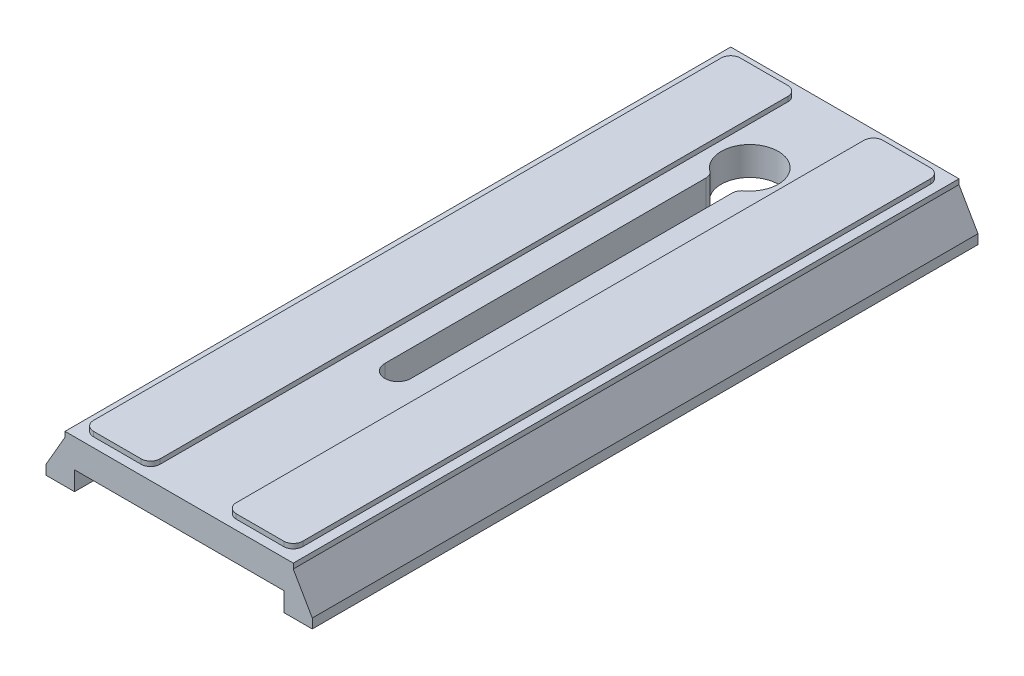
from build123d import *

# Parameters (mm, degrees)
EXTRUDE_1_DEPTH     = 140
CUT_EXTRUDE_1_DEPTH = 4
CUT_EXTRUDE_2_DEPTH = 11
SKETCH_4_R          = 6
CUT_EXTRUDE_3_DEPTH = 11
SKETCH_5_W          = 14
SKETCH_5_H          = 136
EXTRUDE_2_DEPTH     = 1
FILLET_1_R          = 2


with BuildPart() as part:
    # Эскиз1 → Бобышка-Вытянуть1 (new body)
    with BuildSketch(Plane.XY):
        Polygon((-28, 0), (28, 0), (28, 2), (24, 8.92820323), (24, 10), (-24, 10), (-24, 8.92820323), (-28, 2), align=None)
    extrude(amount=EXTRUDE_1_DEPTH)

    # Эскиз2 → Вырез-Вытянуть1 (cut)
    with BuildSketch(Plane.XZ):
        Polygon((-22, 140), (-22, 131), (-17, 116), (-17, 112), (-21, 112), (-21, 28), (-17, 28), (-17, 24), (-22, 9), (-22, 0), (22, 0), (22, 9), (17, 24), (17, 28), (21, 28), (21, 112), (17, 112), (17, 116), (22, 131), (22, 140), align=None)
    extrude(amount=-CUT_EXTRUDE_1_DEPTH, mode=Mode.SUBTRACT)

    # Эскиз3 → Вырез-Вытянуть2 (cut, through all)
    with BuildSketch(Plane(origin=(0, 10, 0), x_dir=(1, 0, 0), z_dir=(0, 1, 0))):
        with BuildLine():
            Line((2.75, -20), (2.75, -94))
            ThreePointArc((2.75, -94), (0, -96.75), (-2.75, -94))
            Line((-2.75, -94), (-2.75, -20))
            ThreePointArc((-2.75, -20), (0, -17.25), (2.75, -20))
        make_face()
    extrude(amount=-CUT_EXTRUDE_2_DEPTH, mode=Mode.SUBTRACT)

    # Эскиз4 → Вырез-Вытянуть3 (cut, through all)
    with BuildSketch(Plane(origin=(0, 10, 0), x_dir=(1, 0, 0), z_dir=(0, 1, 0))):
        with Locations((0, -20)):
            Circle(SKETCH_4_R)
    extrude(amount=-CUT_EXTRUDE_3_DEPTH, mode=Mode.SUBTRACT)

    # Эскиз5 → Бобышка-Вытянуть2 (add)
    with BuildSketch(Plane(origin=(0, 10, 0), x_dir=(1, 0, 0), z_dir=(0, 1, 0))):
        with Locations((15, -70)):
            Rectangle(SKETCH_5_W, SKETCH_5_H)
        with Locations((-15, -70)):
            Rectangle(SKETCH_5_W, SKETCH_5_H)
    extrude(amount=EXTRUDE_2_DEPTH)

    # Скругление1
    fillet_1_edges = [part.edges().sort_by_distance(p)[0] for p in [
        (2.75, 7, 25.332682252),
        (-8, 10.5, 138),
        (-8, 10.5, 2),
        (-22, 10.5, 2),
        (-22, 10.5, 138),
        (22, 10.5, 138),
        (22, 10.5, 2),
        (8, 10.5, 2),
        (8, 10.5, 138),
        (-2.75, 7, 25.332682252),
    ]]
    fillet(fillet_1_edges, radius=FILLET_1_R)


solid = part.part
